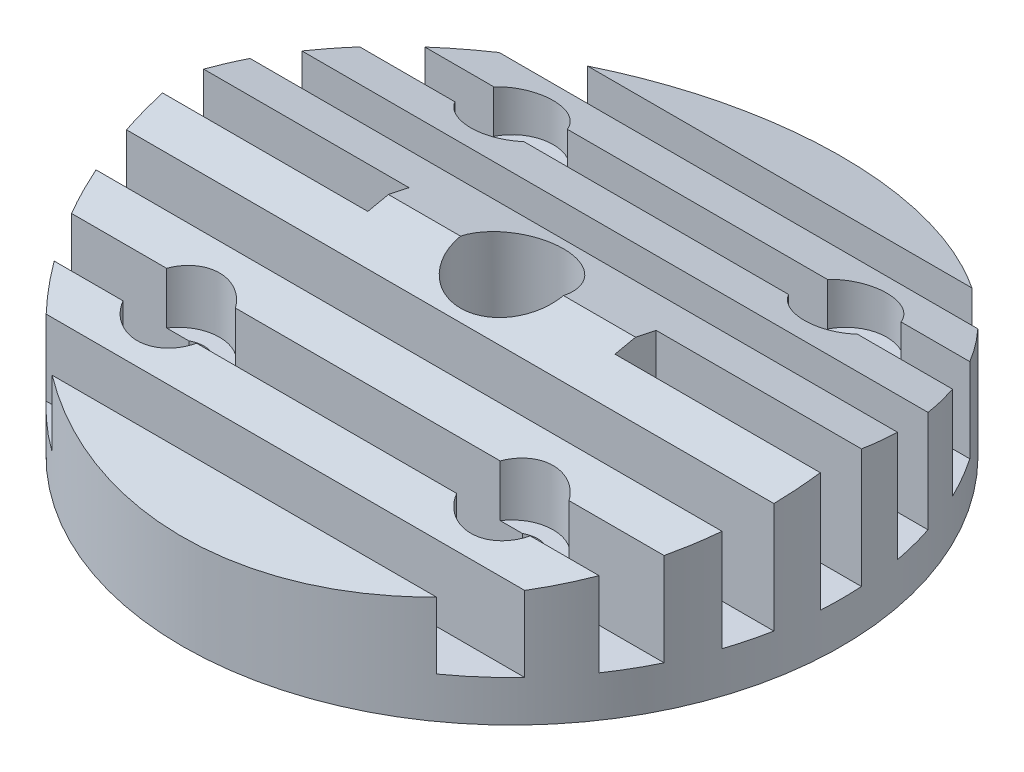
from build123d import *

# Parameters (mm, degrees)
SKETCH2_R                                        = 16
BOSS_EXTRUDE1_DEPTH                              = 8
SKETCH3_W                                        = 27.624731793
SKETCH3_H                                        = 2
SKETCH3_W_2                                      = 37.15735793
SKETCH3_W_3                                      = 33.69266167
SKETCH3_W_4                                      = 12.751314483
CUT_EXTRUDE1_DEPTH                               = 6
SKETCH4_R                                        = 2.5
CUT_EXTRUDE2_DEPTH                               = 4
TAP_DRILL_FOR_M3X0_5_TAP1_D                      = 2.5
TAP_DRILL_FOR_M3X0_5_TAP1_DEPTH                  = 5.5
TAP_DRILL_FOR_M3X0_5_TAP1_TIP                    = 0.751075774
SKETCH8_R                                        = 9
SKETCH8_R_2                                      = 8
BOSS_EXTRUDE2_DEPTH                              = 0.5
CBORE_FOR_M4_PAN_HEAD_MACHINE_SCREW1_D           = 2.5
CBORE_FOR_M4_PAN_HEAD_MACHINE_SCREW1_DEPTH       = 8.001
CBORE_FOR_M4_PAN_HEAD_MACHINE_SCREW1_CBORE_D     = 4
CBORE_FOR_M4_PAN_HEAD_MACHINE_SCREW1_CBORE_DEPTH = 4
CIRPATTERN1_COUNT                                = 4
CUT_EXTRUDE3_DEPTH                               = 20.25


with BuildPart() as part:
    # Sketch2 → Boss-Extrude1 (new body)
    with BuildSketch(Plane(origin=(0, 0, 0), x_dir=(1, 0, 0), z_dir=(0, 1, 0))):
        with Locations(Location((0, 0, 0), (0, 0, 270))):  # turned: the seam where the file's is
            Circle(SKETCH2_R)
    extrude(amount=BOSS_EXTRUDE1_DEPTH)

    # Sketch3 → Cut-Extrude1 (cut)
    with BuildSketch(Plane(origin=(0, 8, 0), x_dir=(1, 0, 0), z_dir=(0, 1, 0))):
        with Locations((0.605596929, -12)):
            Rectangle(SKETCH3_W, SKETCH3_H)
        with Locations((-0.172635518, 4)):
            Rectangle(SKETCH3_W_2, SKETCH3_H)
        with Locations((-0.604755395, 8)):
            Rectangle(SKETCH3_W_3, SKETCH3_H)
        with Locations((0.605596929, 12)):
            Rectangle(SKETCH3_W, SKETCH3_H)
        with Locations((-0.604755395, -8)):
            Rectangle(SKETCH3_W_3, SKETCH3_H)
        with Locations((-0.172635518, -4)):
            Rectangle(SKETCH3_W_2, SKETCH3_H)
        with Locations((-12.375657242, 0)):
            Rectangle(SKETCH3_W_4, SKETCH3_H)
        with Locations((12.375657242, 0)):
            Rectangle(SKETCH3_W_4, SKETCH3_H)
    extrude(amount=-CUT_EXTRUDE1_DEPTH, mode=Mode.SUBTRACT)

    # Sketch4 → Cut-Extrude2 (cut)
    with BuildSketch(Plane(origin=(0, 8, 0), x_dir=(1, 0, 0), z_dir=(0, 1, 0))):
        with Locations(Location((0, 0, 0), (0, 0, 270))):  # turned: the seam where the file's is
            Circle(SKETCH4_R)
    extrude(amount=-CUT_EXTRUDE2_DEPTH, mode=Mode.SUBTRACT)

    # Tap Drill for M3x0.5 Tap1
    with Locations(Plane(origin=(0, 0, 0), x_dir=(-1, 0, 0), z_dir=(0, -1, 0))):
        with Locations((0, 0)):
            Hole(TAP_DRILL_FOR_M3X0_5_TAP1_D / 2, depth=TAP_DRILL_FOR_M3X0_5_TAP1_DEPTH)
            with Locations((0, 0, -(TAP_DRILL_FOR_M3X0_5_TAP1_DEPTH + TAP_DRILL_FOR_M3X0_5_TAP1_TIP / 2))):  # 118° drill point
                Cone(0, TAP_DRILL_FOR_M3X0_5_TAP1_D / 2, TAP_DRILL_FOR_M3X0_5_TAP1_TIP, mode=Mode.SUBTRACT)

    # Sketch8 → Boss-Extrude2 (add)
    with BuildSketch(Plane.XZ):
        with Locations(Location((0, 0, 0), (0, 0, 90))):  # turned: the seam where the file's is
            Circle(SKETCH8_R)
        with Locations(Location((0, 0, 0), (0, 0, 270))):  # turned: the seam where the file's is
            Circle(SKETCH8_R_2, mode=Mode.SUBTRACT)
    extrude(amount=BOSS_EXTRUDE2_DEPTH)

    # CBORE for M4 Pan Head Machine Screw1
    with Locations(Plane(origin=(0, 8, 0), x_dir=(1, 0, 0), z_dir=(0, 1, 0))):
        with Locations((-8.1, -8.1)):
            cbore_for_m4_pan_head_machine_screw1 = CounterBoreHole(CBORE_FOR_M4_PAN_HEAD_MACHINE_SCREW1_D / 2, CBORE_FOR_M4_PAN_HEAD_MACHINE_SCREW1_CBORE_D / 2, CBORE_FOR_M4_PAN_HEAD_MACHINE_SCREW1_CBORE_DEPTH, depth=CBORE_FOR_M4_PAN_HEAD_MACHINE_SCREW1_DEPTH)

    # CirPattern1: CBORE for M4 Pan Head Machine Screw1 ×4 about axis
    cirpattern1_axis = Axis((0, 0, 0), (0, 1, 0))
    for i in range(1, CIRPATTERN1_COUNT):
        add(cbore_for_m4_pan_head_machine_screw1.rotate(cirpattern1_axis, i * 360 / CIRPATTERN1_COUNT), mode=Mode.SUBTRACT)

    # Sketch12 → Cut-Extrude3 (cut, symmetric)
    with BuildSketch(Plane(origin=(0, 0, 0), x_dir=(0, 0, -1), z_dir=(1, 0, 0))):
        Polygon((0, 8), (16, 8), (17.032384138, 8), (17.032384138, 4.379654991), align=None)
    cut_extrude3 = extrude(amount=CUT_EXTRUDE3_DEPTH, both=True, mode=Mode.SUBTRACT)

    # Mirror1: Cut-Extrude3 across plane
    add(cut_extrude3.mirror(Plane.XY), mode=Mode.SUBTRACT)


solid = part.part
